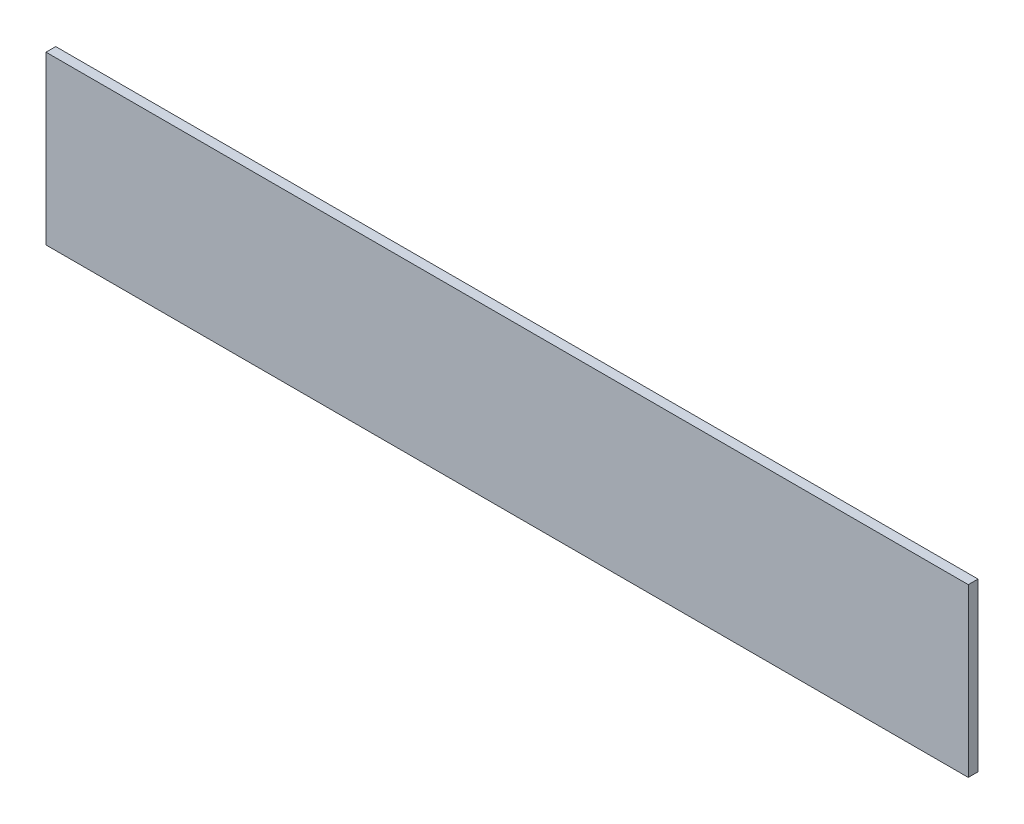
from build123d import *

# Parameters (mm, degrees)
SKETCH1_W           = 475
SKETCH1_H           = 86
BOSS_EXTRUDE1_DEPTH = 5


with BuildPart() as part:
    # Sketch1 → Boss-Extrude1 (new body)
    with BuildSketch(Plane.XY):
        Rectangle(SKETCH1_W, SKETCH1_H)
    extrude(amount=BOSS_EXTRUDE1_DEPTH)


solid = part.part
